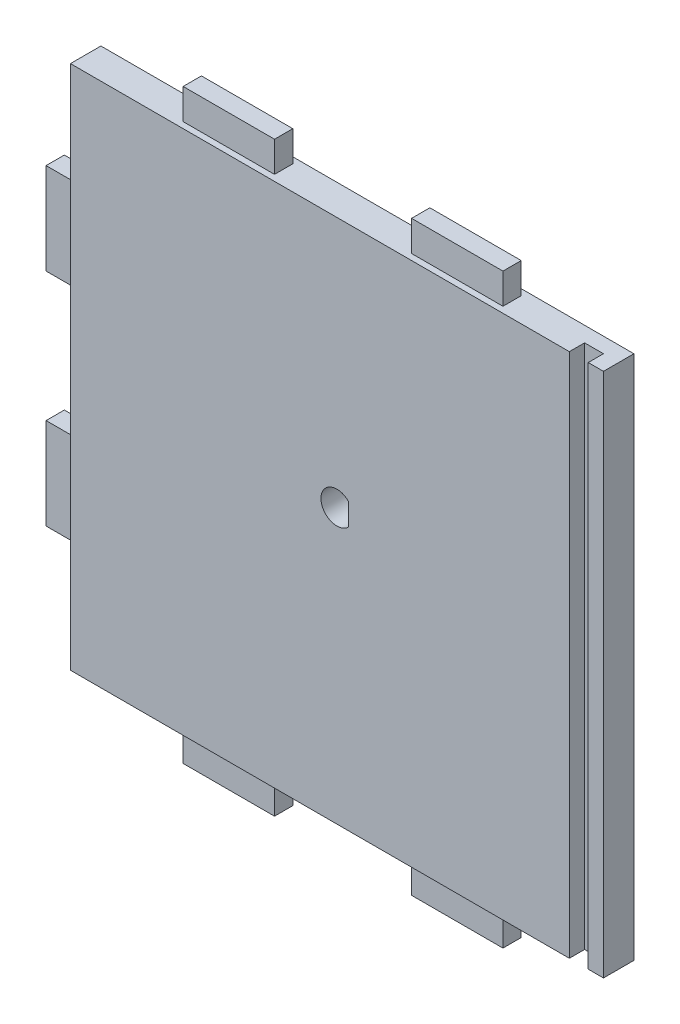
from build123d import *

# Parameters (mm, degrees)
ESBO_O1_W                = 175
ESBO_O1_H                = 172.5
RESSALTO_EXTRUS_O1_DEPTH = 10
ESBO_O5_W                = 30
ESBO_O5_H                = 6
RESSALTO_EXTRUS_O5_DEPTH = 10
ESBO_O6_W                = 6
ESBO_O6_H                = 30
RESSALTO_EXTRUS_O6_DEPTH = 10
ESBO_O7_W                = 30
ESBO_O7_H                = 6
RESSALTO_EXTRUS_O7_DEPTH = 10
ESBO_O9_W                = 6.2
ESBO_O9_H                = 172.5
CORTE_EXTRUS_O2_DEPTH    = 5
ESBO_O10_R               = 1.5
CORTE_EXTRUS_O3_DEPTH    = 8
ESBO_O11_R               = 1.5
CORTE_EXTRUS_O4_DEPTH    = 8
CORTE_EXTRUS_O5_DEPTH    = 11


with BuildPart() as part:
    # Esboço1 → Ressalto-extrusão1 (new body)
    with BuildSketch(Plane.XY):
        Rectangle(ESBO_O1_W, ESBO_O1_H)
    extrude(amount=RESSALTO_EXTRUS_O1_DEPTH)

    # Esboço5 → Ressalto-extrusão5 (add)
    with BuildSketch(Plane(origin=(0, 86.25, 0), x_dir=(1, 0, 0), z_dir=(0, 1, 0))):
        with Locations((-37.5, -5)):
            Rectangle(ESBO_O5_W, ESBO_O5_H)
        with Locations((37.5, -5)):
            Rectangle(ESBO_O5_W, ESBO_O5_H)
    extrude(amount=RESSALTO_EXTRUS_O5_DEPTH)

    # Esboço6 → Ressalto-extrusão6 (add)
    with BuildSketch(Plane.ZY.offset(87.5)):
        with Locations((5, 36.25)):
            Rectangle(ESBO_O6_W, ESBO_O6_H)
        with Locations((5, -36.25)):
            Rectangle(ESBO_O6_W, ESBO_O6_H)
    extrude(amount=RESSALTO_EXTRUS_O6_DEPTH)

    # Esboço7 → Ressalto-extrusão7 (add)
    with BuildSketch(Plane.XZ.offset(86.25)):
        with Locations((-37.5, 5)):
            Rectangle(ESBO_O7_W, ESBO_O7_H)
        with Locations((37.5, 5)):
            Rectangle(ESBO_O7_W, ESBO_O7_H)
    extrude(amount=RESSALTO_EXTRUS_O7_DEPTH)

    # Esboço9 → Corte-extrusão2 (cut)
    with BuildSketch(Plane.XY.offset(10)):
        with Locations((79.4, 0)):
            Rectangle(ESBO_O9_W, ESBO_O9_H)
    extrude(amount=-CORTE_EXTRUS_O2_DEPTH, mode=Mode.SUBTRACT)

    # Esboço10 → Corte-extrusão3 (cut)
    with BuildSketch(Plane.ZY.offset(87.5)):
        with Locations((5, -71.25)):
            Circle(ESBO_O10_R)
    extrude(amount=-CORTE_EXTRUS_O3_DEPTH, mode=Mode.SUBTRACT)

    # Esboço11 → Corte-extrusão4 (cut)
    with BuildSketch(Plane.XZ.offset(86.25)):
        with Locations((65, 5)):
            Circle(ESBO_O11_R)
    extrude(amount=-CORTE_EXTRUS_O4_DEPTH, mode=Mode.SUBTRACT)

    # Esboço12 → Corte-extrusão5 (cut, through all)
    with BuildSketch(Plane(origin=(0, 0, 0), x_dir=(-1, 0, 0), z_dir=(0, 0, -1))):
        with BuildLine():
            Line((-3.85, 7.31931366), (-3.85, 0.18068634))
            ThreePointArc((-3.85, 0.18068634), (1.917028951, -1.137484015), (5.25, 3.75))
            ThreePointArc((5.25, 3.75), (1.917028951, 8.637484015), (-3.85, 7.31931366))
        make_face()
    extrude(amount=-CORTE_EXTRUS_O5_DEPTH, mode=Mode.SUBTRACT)


solid = part.part
